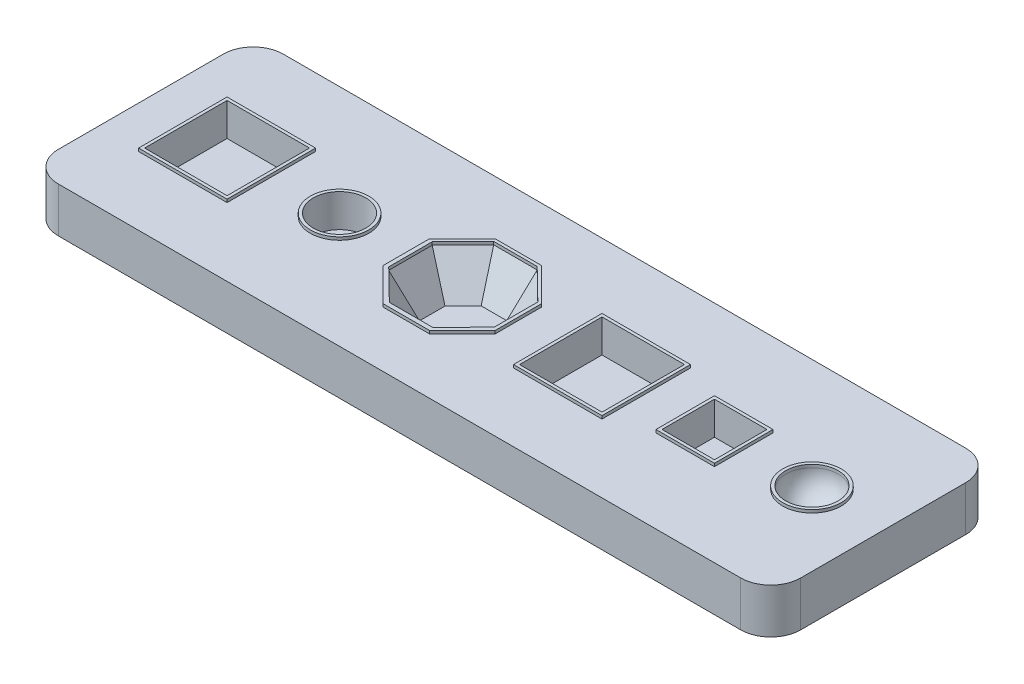
from build123d import *

# Parameters (mm, degrees)
SKETCH1_W           = 495
SKETCH1_H           = 150
BOSS_EXTRUDE1_DEPTH = 30
SKETCH2_R           = 17.5
SKETCH2_W           = 55
SKETCH2_H           = 55
CUT_EXTRUDE1_DEPTH  = 20
CUT_EXTRUDE2_DEPTH  = 25
CUT_EXTRUDE2_TAPER  = 30
SKETCH5_W           = 55
SKETCH5_H           = 55
SKETCH5_W_2         = 35
SKETCH5_H_2         = 35
CUT_EXTRUDE3_DEPTH  = 20
FILLET1_R           = 20
SKETCH8_W           = 59
SKETCH8_H           = 59
SKETCH8_W_2         = 55
SKETCH8_H_2         = 55
BOSS_EXTRUDE2_DEPTH = 2
SKETCH9_R           = 19.5
SKETCH9_R_2         = 17.5
BOSS_EXTRUDE3_DEPTH = 2
BOSS_EXTRUDE4_DEPTH = 2
SKETCH11_W          = 59
SKETCH11_H          = 59
SKETCH11_W_2        = 55
SKETCH11_H_2        = 55
BOSS_EXTRUDE6_DEPTH = 2
SKETCH12_W          = 39
SKETCH12_H          = 39
SKETCH12_W_2        = 35
SKETCH12_H_2        = 35
BOSS_EXTRUDE7_DEPTH = 2
SKETCH13_R          = 19.5
SKETCH13_R_2        = 17.5
BOSS_EXTRUDE8_DEPTH = 2


with BuildPart() as part:
    # Sketch1 → Boss-Extrude1 (new body)
    with BuildSketch(Plane(origin=(0, 0, 0), x_dir=(1, 0, 0), z_dir=(0, 1, 0))):
        Rectangle(SKETCH1_W, SKETCH1_H)
    extrude(amount=BOSS_EXTRUDE1_DEPTH)

    # Sketch2 → Cut-Extrude1 (cut)
    with BuildSketch(Plane(origin=(0, 30, 0), x_dir=(1, 0, 0), z_dir=(0, 1, 0))):
        with Locations((-115, 0)):
            Circle(SKETCH2_R)
        with Locations((-190, 0)):
            Rectangle(SKETCH2_W, SKETCH2_H)
    extrude(amount=-CUT_EXTRUDE1_DEPTH, mode=Mode.SUBTRACT)

    # Sketch4 → Cut-Extrude2 (cut)
    with BuildSketch(Plane(origin=(0, 30, 0), x_dir=(1, 0, 0), z_dir=(0, 1, 0))):
        Polygon((-67.5, 14.287926899), (-67.5, -14.712073101), (-46.782926899, -35.005), (-17.782926899, -35.005), (2.51, -14.287926899), (2.51, 14.712073101), (-18.207073101, 35.005), (-47.207073101, 35.005), align=None)
    extrude(amount=-CUT_EXTRUDE2_DEPTH, taper=CUT_EXTRUDE2_TAPER, mode=Mode.SUBTRACT)

    # Sketch5 → Cut-Extrude3 (cut)
    with BuildSketch(Plane(origin=(0, 30, 0), x_dir=(1, 0, 0), z_dir=(0, 1, 0))):
        with Locations((60.01, 0)):
            Rectangle(SKETCH5_W, SKETCH5_H)
        with Locations((135.01, 0)):
            Rectangle(SKETCH5_W_2, SKETCH5_H_2)
    extrude(amount=-CUT_EXTRUDE3_DEPTH, mode=Mode.SUBTRACT)

    # Sketch6 → Cut-Revolve1 (revolve, cut)
    with BuildSketch(Plane(origin=(0, 30, 0), x_dir=(1, 0, 0), z_dir=(0, 1, 0))):
        with BuildLine():
            Line((217.51, 0), (182.51, 0))
            ThreePointArc((182.51, 0), (200.01, 17.5), (217.51, 0))
        make_face()
    revolve(axis=Axis((217.51, 30, 0), (-1, 0, 0)), mode=Mode.SUBTRACT)

    # Fillet1
    fillet1_edges = [part.edges().sort_by_distance(p)[0] for p in [
        (247.5, 15, 75),
        (-247.5, 15, 75),
        (-247.5, 15, -75),
        (247.5, 15, -75),
    ]]
    fillet(fillet1_edges, radius=FILLET1_R)

    # Sketch8 → Boss-Extrude2 (add)
    with BuildSketch(Plane(origin=(0, 30, 0), x_dir=(1, 0, 0), z_dir=(0, 1, 0))):
        with Locations((-190, 0)):
            Rectangle(SKETCH8_W, SKETCH8_H)
        with Locations((-190, 0)):
            Rectangle(SKETCH8_W_2, SKETCH8_H_2, mode=Mode.SUBTRACT)
    extrude(amount=BOSS_EXTRUDE2_DEPTH)

    # Sketch9 → Boss-Extrude3 (add)
    with BuildSketch(Plane(origin=(0, 30, 0), x_dir=(1, 0, 0), z_dir=(0, 1, 0))):
        with Locations((-115, 0)):
            Circle(SKETCH9_R)
        with Locations((-115, 0)):
            Circle(SKETCH9_R_2, mode=Mode.SUBTRACT)
    extrude(amount=BOSS_EXTRUDE3_DEPTH)

    # Sketch10 → Boss-Extrude4 (add)
    with BuildSketch(Plane(origin=(0, 30, 0), x_dir=(1, 0, 0), z_dir=(0, 1, 0))):
        Polygon((-48.207073101, 37.005), (-17.207073101, 37.005), (4.713237116, 15.084689783), (4.713237116, -15.915310217), (-17.207073101, -37.835620434), (-48.207073101, -37.835620434), (-70.127383317, -15.915310217), (-70.127383317, 15.084689783), align=None)
        Polygon((-47.207073101, 35.005), (-18.207073101, 35.005), (2.51, 14.712073101), (2.51, -14.287926899), (-17.782926899, -35.005), (-46.782926899, -35.005), (-67.5, -14.712073101), (-67.5, 14.287926899), align=None, mode=Mode.SUBTRACT)
    extrude(amount=BOSS_EXTRUDE4_DEPTH)

    # Sketch11 → Boss-Extrude6 (add)
    with BuildSketch(Plane(origin=(0, 30, 0), x_dir=(1, 0, 0), z_dir=(0, 1, 0))):
        with Locations((60.01, 0)):
            Rectangle(SKETCH11_W, SKETCH11_H)
        with Locations((60.01, 0)):
            Rectangle(SKETCH11_W_2, SKETCH11_H_2, mode=Mode.SUBTRACT)
    extrude(amount=BOSS_EXTRUDE6_DEPTH)

    # Sketch12 → Boss-Extrude7 (add)
    with BuildSketch(Plane(origin=(0, 30, 0), x_dir=(1, 0, 0), z_dir=(0, 1, 0))):
        with Locations((135.01, 0)):
            Rectangle(SKETCH12_W, SKETCH12_H)
        with Locations((135.01, 0)):
            Rectangle(SKETCH12_W_2, SKETCH12_H_2, mode=Mode.SUBTRACT)
    extrude(amount=BOSS_EXTRUDE7_DEPTH)

    # Sketch13 → Boss-Extrude8 (add)
    with BuildSketch(Plane(origin=(0, 30, 0), x_dir=(1, 0, 0), z_dir=(0, 1, 0))):
        with Locations((200.01, 0)):
            Circle(SKETCH13_R)
        with Locations((200.01, 0)):
            Circle(SKETCH13_R_2, mode=Mode.SUBTRACT)
    extrude(amount=BOSS_EXTRUDE8_DEPTH)


solid = part.part
